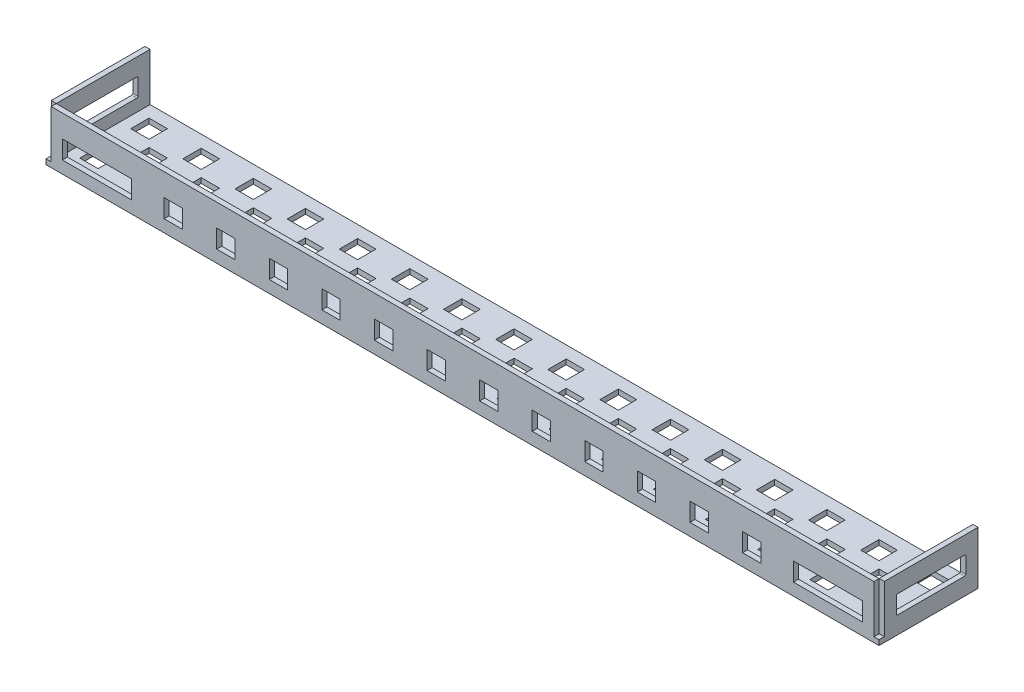
from build123d import *

# Parameters (mm, degrees)
SKETCH1_W           = 204.5
SKETCH1_H           = 23
BOSS_EXTRUDE1_DEPTH = 1.25
SKETCH2_W           = 1.25
SKETCH2_H           = 23
BOSS_EXTRUDE2_DEPTH = 11.75
CUT_EXTRUDE1_DEPTH  = 220
SKETCH4_W           = 4.5
SKETCH4_H           = 4.5
CUT_EXTRUDE2_DEPTH  = 220
SKETCH5_W           = 204.5
SKETCH5_H           = 1.25
BOSS_EXTRUDE4_DEPTH = 13
SKETCH6_W           = 204.5
SKETCH6_H           = 0.05
BOSS_EXTRUDE5_DEPTH = 1.25
SKETCH7_W           = 17
SKETCH7_H           = 4.5
SKETCH7_W_2         = 4.5
CUT_EXTRUDE3_DEPTH  = 1.25
SKETCH8_W           = 1.25
SKETCH8_H           = 13
CUT_EXTRUDE4_DEPTH  = 1.25
SKETCH9_W           = 1.25
SKETCH9_H           = 1.25
BOSS_EXTRUDE6_DEPTH = 1.25


with BuildPart() as part:
    # Sketch1 → Boss-Extrude1 (new body)
    with BuildSketch(Plane(origin=(0, 0, 0), x_dir=(1, 0, 0), z_dir=(0, 1, 0))):
        with Locations((-102.25, 11.5)):
            Rectangle(SKETCH1_W, SKETCH1_H)
    extrude(amount=BOSS_EXTRUDE1_DEPTH)

    # Sketch2 → Boss-Extrude2 (add)
    with BuildSketch(Plane(origin=(0, 1.25, 0), x_dir=(1, 0, 0), z_dir=(0, 1, 0))):
        with Locations((-203.875, 11.5)):
            Rectangle(SKETCH2_W, SKETCH2_H)
        with Locations((-0.625, 11.5)):
            Rectangle(SKETCH2_W, SKETCH2_H)
    extrude(amount=BOSS_EXTRUDE2_DEPTH)

    # Sketch3 → Cut-Extrude1 (cut)
    with BuildSketch(Plane(origin=(0, 0, 0), x_dir=(0, 0, -1), z_dir=(1, 0, 0))):
        with BuildLine():
            Line((3.25, 8.75), (19.75, 8.75))
            ThreePointArc((19.75, 8.75), (19.926776695, 8.676776695), (20, 8.5))
            Line((20, 8.5), (20, 4.5))
            ThreePointArc((20, 4.5), (19.926776695, 4.323223305), (19.75, 4.25))
            Line((19.75, 4.25), (3.25, 4.25))
            ThreePointArc((3.25, 4.25), (3.073223305, 4.323223305), (3, 4.5))
            Line((3, 4.5), (3, 8.5))
            ThreePointArc((3, 8.5), (3.073223305, 8.676776695), (3.25, 8.75))
        make_face()
    extrude(amount=-CUT_EXTRUDE1_DEPTH, mode=Mode.SUBTRACT)

    # Sketch4 → Cut-Extrude2 (cut)
    with BuildSketch(Plane.XZ):
        with Locations((-198.25, -5.25)):
            Rectangle(SKETCH4_W, SKETCH4_H)
        with Locations((-198.25, -17.75)):
            Rectangle(SKETCH4_W, SKETCH4_H)
        with Locations((-185.45, -5.25)):
            Rectangle(SKETCH4_W, SKETCH4_H)
        with Locations((-192, -11.5)):
            Rectangle(SKETCH4_W, SKETCH4_H)
        with Locations((-185.45, -17.75)):
            Rectangle(SKETCH4_W, SKETCH4_H)
        with Locations((-179.2, -11.5)):
            Rectangle(SKETCH4_W, SKETCH4_H)
        with Locations((-172.65, -5.25)):
            Rectangle(SKETCH4_W, SKETCH4_H)
        with Locations((-172.65, -17.75)):
            Rectangle(SKETCH4_W, SKETCH4_H)
        with Locations((-166.4, -11.5)):
            Rectangle(SKETCH4_W, SKETCH4_H)
        with Locations((-159.85, -5.25)):
            Rectangle(SKETCH4_W, SKETCH4_H)
        with Locations((-159.85, -17.75)):
            Rectangle(SKETCH4_W, SKETCH4_H)
        with Locations((-153.6, -11.5)):
            Rectangle(SKETCH4_W, SKETCH4_H)
        with Locations((-147.05, -5.25)):
            Rectangle(SKETCH4_W, SKETCH4_H)
        with Locations((-147.05, -17.75)):
            Rectangle(SKETCH4_W, SKETCH4_H)
        with Locations((-140.8, -11.5)):
            Rectangle(SKETCH4_W, SKETCH4_H)
        with Locations((-134.25, -5.25)):
            Rectangle(SKETCH4_W, SKETCH4_H)
        with Locations((-134.25, -17.75)):
            Rectangle(SKETCH4_W, SKETCH4_H)
        with Locations((-128, -11.5)):
            Rectangle(SKETCH4_W, SKETCH4_H)
        with Locations((-121.45, -5.25)):
            Rectangle(SKETCH4_W, SKETCH4_H)
        with Locations((-121.45, -17.75)):
            Rectangle(SKETCH4_W, SKETCH4_H)
        with Locations((-115.2, -11.5)):
            Rectangle(SKETCH4_W, SKETCH4_H)
        with Locations((-108.65, -5.25)):
            Rectangle(SKETCH4_W, SKETCH4_H)
        with Locations((-108.65, -17.75)):
            Rectangle(SKETCH4_W, SKETCH4_H)
        with Locations((-102.4, -11.5)):
            Rectangle(SKETCH4_W, SKETCH4_H)
        with Locations((-95.85, -5.25)):
            Rectangle(SKETCH4_W, SKETCH4_H)
        with Locations((-95.85, -17.75)):
            Rectangle(SKETCH4_W, SKETCH4_H)
        with Locations((-89.6, -11.5)):
            Rectangle(SKETCH4_W, SKETCH4_H)
        with Locations((-83.05, -5.25)):
            Rectangle(SKETCH4_W, SKETCH4_H)
        with Locations((-83.05, -17.75)):
            Rectangle(SKETCH4_W, SKETCH4_H)
        with Locations((-76.8, -11.5)):
            Rectangle(SKETCH4_W, SKETCH4_H)
        with Locations((-70.25, -5.25)):
            Rectangle(SKETCH4_W, SKETCH4_H)
        with Locations((-70.25, -17.75)):
            Rectangle(SKETCH4_W, SKETCH4_H)
        with Locations((-64, -11.5)):
            Rectangle(SKETCH4_W, SKETCH4_H)
        with Locations((-57.45, -5.25)):
            Rectangle(SKETCH4_W, SKETCH4_H)
        with Locations((-57.45, -17.75)):
            Rectangle(SKETCH4_W, SKETCH4_H)
        with Locations((-51.2, -11.5)):
            Rectangle(SKETCH4_W, SKETCH4_H)
        with Locations((-44.65, -5.25)):
            Rectangle(SKETCH4_W, SKETCH4_H)
        with Locations((-44.65, -17.75)):
            Rectangle(SKETCH4_W, SKETCH4_H)
        with Locations((-38.4, -11.5)):
            Rectangle(SKETCH4_W, SKETCH4_H)
        with Locations((-31.85, -5.25)):
            Rectangle(SKETCH4_W, SKETCH4_H)
        with Locations((-31.85, -17.75)):
            Rectangle(SKETCH4_W, SKETCH4_H)
        with Locations((-25.6, -11.5)):
            Rectangle(SKETCH4_W, SKETCH4_H)
        with Locations((-19.05, -5.25)):
            Rectangle(SKETCH4_W, SKETCH4_H)
        with Locations((-19.05, -17.75)):
            Rectangle(SKETCH4_W, SKETCH4_H)
        with Locations((-12.8, -11.5)):
            Rectangle(SKETCH4_W, SKETCH4_H)
        with Locations((-6.25, -5.25)):
            Rectangle(SKETCH4_W, SKETCH4_H)
        with Locations((-6.25, -17.75)):
            Rectangle(SKETCH4_W, SKETCH4_H)
    extrude(amount=-CUT_EXTRUDE2_DEPTH, mode=Mode.SUBTRACT)



with BuildPart() as body_2:
    # Sketch5 → Boss-Extrude4 (new body)
    with BuildSketch(Plane.XZ):
        with Locations((-102.25, 0.675)):
            Rectangle(SKETCH5_W, SKETCH5_H)
    extrude(amount=-BOSS_EXTRUDE4_DEPTH)


with BuildPart() as part_1:
    add(part.part)

    add(body_2.part)  # Boss-Extrude5 merges body 2
    # Sketch6 → Boss-Extrude5 (add)
    with BuildSketch(Plane.XZ):
        with Locations((-102.25, 0.025)):
            Rectangle(SKETCH6_W, SKETCH6_H)
    extrude(amount=-BOSS_EXTRUDE5_DEPTH)

    # Sketch7 → Cut-Extrude3 (cut)
    with BuildSketch(Plane.XY.offset(1.3)):
        with Locations((-192, 5.25)):
            Rectangle(SKETCH7_W, SKETCH7_H)
        with Locations((-12.5, 5.25)):
            Rectangle(SKETCH7_W, SKETCH7_H)
        with Locations((-160.340909091, 5.25)):
            Rectangle(SKETCH7_W_2, SKETCH7_H)
        with Locations((-173.25, 5.25)):
            Rectangle(SKETCH7_W_2, SKETCH7_H)
        with Locations((-147.431818182, 5.25)):
            Rectangle(SKETCH7_W_2, SKETCH7_H)
        with Locations((-134.522727273, 5.25)):
            Rectangle(SKETCH7_W_2, SKETCH7_H)
        with Locations((-121.613636364, 5.25)):
            Rectangle(SKETCH7_W_2, SKETCH7_H)
        with Locations((-108.704545455, 5.25)):
            Rectangle(SKETCH7_W_2, SKETCH7_H)
        with Locations((-95.795454545, 5.25)):
            Rectangle(SKETCH7_W_2, SKETCH7_H)
        with Locations((-82.886363636, 5.25)):
            Rectangle(SKETCH7_W_2, SKETCH7_H)
        with Locations((-69.977272727, 5.25)):
            Rectangle(SKETCH7_W_2, SKETCH7_H)
        with Locations((-57.068181818, 5.25)):
            Rectangle(SKETCH7_W_2, SKETCH7_H)
        with Locations((-44.159090909, 5.25)):
            Rectangle(SKETCH7_W_2, SKETCH7_H)
        with Locations((-31.25, 5.25)):
            Rectangle(SKETCH7_W_2, SKETCH7_H)
    extrude(amount=-CUT_EXTRUDE3_DEPTH, mode=Mode.SUBTRACT)

    # Sketch8 → Cut-Extrude4 (cut)
    with BuildSketch(Plane.XY.offset(1.3)):
        with Locations((-203.875, 6.5)):
            Rectangle(SKETCH8_W, SKETCH8_H)
        with Locations((-0.625, 6.5)):
            Rectangle(SKETCH8_W, SKETCH8_H)
    extrude(amount=-CUT_EXTRUDE4_DEPTH, mode=Mode.SUBTRACT)

    # Sketch9 → Boss-Extrude6 (add)
    with BuildSketch(Plane(origin=(0, 0, 0), x_dir=(-1, 0, 0), z_dir=(0, -1, 0))):
        with Locations((0.625, -0.675)):
            Rectangle(SKETCH9_W, SKETCH9_H)
        with Locations((203.875, -0.675)):
            Rectangle(SKETCH9_W, SKETCH9_H)
    extrude(amount=-BOSS_EXTRUDE6_DEPTH)


solid = part_1.part
